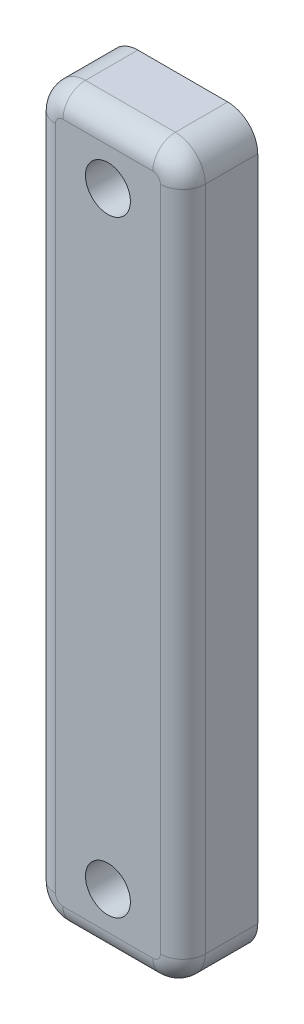
from build123d import *

# Parameters (mm, degrees)
BOSS_EXTRUDE1_DEPTH = 5
SKETCH4_R           = 1.5
CUT_EXTRUDE1_DEPTH  = 6
FILLET1_R           = 1.5


with BuildPart() as part:
    # Sketch2 → Boss-Extrude1 (new body)
    with BuildSketch(Plane.XY):
        with BuildLine():
            Line((8, 20.584180911), (2, 20.584180911))
            ThreePointArc((2, 20.584180911), (0.585786438, 19.998394474), (0, 18.584180911))
            Line((0, 18.584180911), (0, -25.915819089))
            ThreePointArc((0, -25.915819089), (0.585786438, -27.330032651), (2, -27.915819089))
            Line((2, -27.915819089), (8, -27.915819089))
            ThreePointArc((8, -27.915819089), (9.414213562, -27.330032651), (10, -25.915819089))
            Line((10, -25.915819089), (10, 18.584180911))
            ThreePointArc((10, 18.584180911), (9.414213562, 19.998394474), (8, 20.584180911))
        make_face()
    extrude(amount=BOSS_EXTRUDE1_DEPTH)

    # Sketch4 → Cut-Extrude1 (cut, through all)
    with BuildSketch(Plane(origin=(0, 0, 0), x_dir=(-1, 0, 0), z_dir=(0, 0, -1))):
        with Locations((-5, -23.915819089)):
            Circle(SKETCH4_R)
        with Locations((-5, 16.584180911)):
            Circle(SKETCH4_R)
    extrude(amount=-CUT_EXTRUDE1_DEPTH, mode=Mode.SUBTRACT)

    # Fillet1
    fillet1_edges = [part.edges().sort_by_distance(p)[0] for p in [
        (0.585786438, 19.998394474, 5),
        (0, -3.665819089, 5),
        (0.585786438, -27.330032651, 5),
        (5, -27.915819089, 5),
        (9.414213562, -27.330032651, 5),
        (10, -3.665819089, 5),
        (9.414213562, 19.998394474, 5),
        (5, 20.584180911, 5),
    ]]
    fillet(fillet1_edges, radius=FILLET1_R)


solid = part.part
